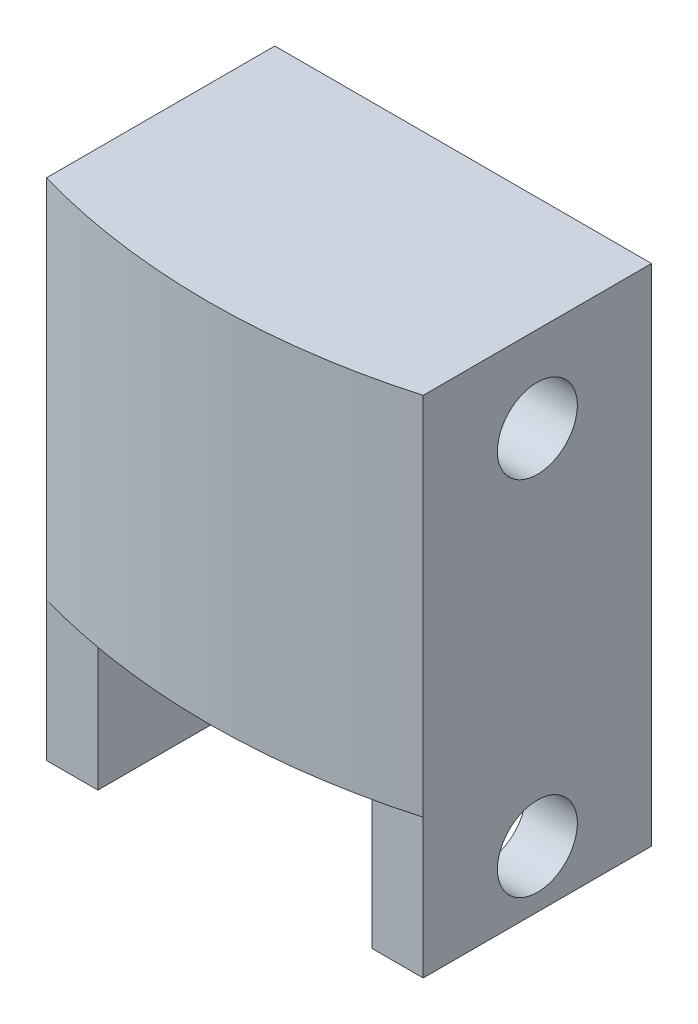
from build123d import *

# Parameters (mm, degrees)
BOSS_EXTRUDE1_DEPTH = 32
SKETCH3_W           = 20
SKETCH3_H           = 12.2
BOSS_EXTRUDE2_DEPTH = 4.5
SKETCH4_R           = 3.5
CUT_EXTRUDE1_DEPTH  = 34
SKETCH5_R           = 3.5
CUT_EXTRUDE2_DEPTH  = 9
FILLET1_R           = 2.5


with BuildPart() as part:
    # Sketch1 → Boss-Extrude1 (new body)
    with BuildSketch(Plane(origin=(0, 0, 0), x_dir=(1, 0, 0), z_dir=(0, 1, 0))):
        with BuildLine():
            Line((-16.5, 10), (16.5, 10))
            Line((16.5, 10), (16.5, -10))
            ThreePointArc((16.5, -10), (0, -12.313346431), (-16.5, -10))
            Line((-16.5, -10), (-16.5, 10))
        make_face()
    extrude(amount=BOSS_EXTRUDE1_DEPTH)

    # Sketch3 → Boss-Extrude2 (add)
    with BuildSketch(Plane.ZY.offset(16.5)):
        with Locations((0, -6.1)):
            Rectangle(SKETCH3_W, SKETCH3_H)
    boss_extrude2 = extrude(amount=-BOSS_EXTRUDE2_DEPTH)

    # Mirror1: Boss-Extrude2 across plane
    add(boss_extrude2.mirror(Plane(origin=(0, 0, 0), x_dir=(0, 0, 1), z_dir=(1, 0, 0))))

    # Sketch4 → Cut-Extrude1 (cut, through all)
    with BuildSketch(Plane.ZY.offset(16.5)):
        with Locations((0, -7.2)):
            Circle(SKETCH4_R)
    extrude(amount=-CUT_EXTRUDE1_DEPTH, mode=Mode.SUBTRACT)

    # Sketch5 → Cut-Extrude2 (cut)
    with BuildSketch(Plane.ZY.offset(-16.5)):
        with Locations((0, 24.5)):
            Circle(SKETCH5_R)
    extrude(amount=CUT_EXTRUDE2_DEPTH, mode=Mode.SUBTRACT)

    # Fillet1
    fillet1_edges = [part.edges().sort_by_distance(p)[0] for p in [
        (-12, -6.1, -10),
        (12, -6.1, -10),
    ]]
    fillet(fillet1_edges, radius=FILLET1_R)


solid = part.part
